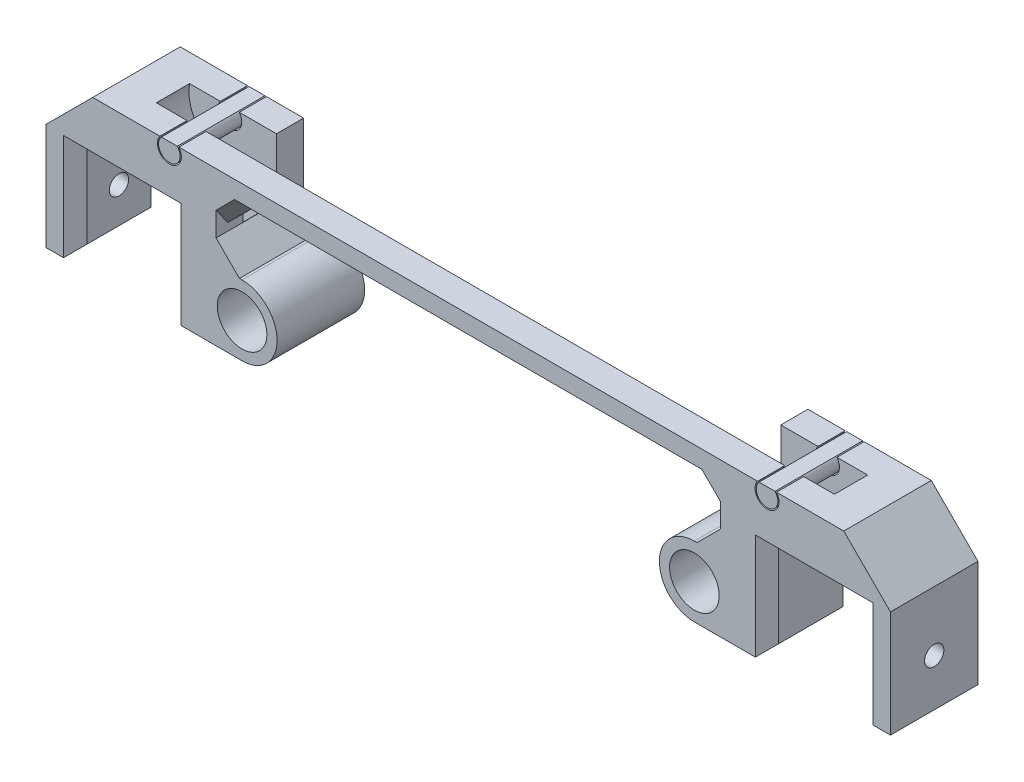
from build123d import *

# Parameters (mm, degrees)
BOSS_EXTRUDE1_DEPTH       = 19.05
M5X0_8_TAPPED_HOLE1_D     = 4.2
M5X0_8_TAPPED_HOLE1_DEPTH = 6.35
SKETCH2_R                 = 8.89
CUT_EXTRUDE1_DEPTH        = 3.6195
BOSS_EXTRUDE2_DEPTH       = 19.05
BOSS_EXTRUDE2_2_DEPTH     = 19.05
CHAMFER1_SIZE             = 2.54
CHAMFER2_SIZE             = 10.16
CHAMFER1_OF_MIRROR1_SIZE  = 2.54
CHAMFER2_OF_MIRROR1_SIZE  = 10.16
SKETCH4_W                 = 109.728
SKETCH4_H                 = 13.1445
CUT_EXTRUDE2_DEPTH        = 34.3883
CHAMFER3_SIZE             = 2.54
CHAMFER6_SIZE             = 5.08
SKETCH5_R                 = 5.3975
BOSS_EXTRUDE3_DEPTH       = 19.05
SKETCH6_R                 = 1.905
BOSS_EXTRUDE4_DEPTH       = 1.778
BOSS_EXTRUDE4_TAPER       = 22.5
CHAMFER7_SIZE             = 5.08
CHAMFER4_SIZE             = 2.54
CHAMFER5_SIZE             = 2.54


with BuildPart() as part:
    # Sketch1 → Boss-Extrude1 (new body)
    with BuildSketch(Plane.XY):
        with BuildLine():
            Line((-54.864, -27.0383), (-54.864, 0))
            Line((-54.864, 0), (54.864, 0))
            Line((54.864, 0), (54.864, -27.0383))
            Line((54.864, -27.0383), (65.024, -27.0383))
            Line((65.024, -27.0383), (65.024, -6.5405))
            Line((65.024, -6.5405), (85.5218, -6.5405))
            Line((85.5218, -6.5405), (85.5218, -27.0383))
            Line((85.5218, -27.0383), (91.8718, -27.0383))
            Line((91.8718, -27.0383), (91.8718, 6.35))
            Line((91.8718, 6.35), (67.087505755, 6.35))
            ThreePointArc((67.087505755, 6.35), (67.488807242, 5.600913686), (67.6275, 4.7625))
            ThreePointArc((67.6275, 4.7625), (64.185586314, 2.297692758), (62.960494245, 6.35))
            Line((62.960494245, 6.35), (-62.960494245, 6.35))
            ThreePointArc((-62.960494245, 6.35), (-62.559192758, 5.600913686), (-62.4205, 4.7625))
            ThreePointArc((-62.4205, 4.7625), (-65.862413686, 2.297692758), (-67.087505755, 6.35))
            Line((-67.087505755, 6.35), (-91.8718, 6.35))
            Line((-91.8718, 6.35), (-91.8718, -27.0383))
            Line((-91.8718, -27.0383), (-85.5218, -27.0383))
            Line((-85.5218, -27.0383), (-85.5218, -6.5405))
            Line((-85.5218, -6.5405), (-65.024, -6.5405))
            Line((-65.024, -6.5405), (-65.024, -27.0383))
            Line((-65.024, -27.0383), (-54.864, -27.0383))
        make_face()
    extrude(amount=BOSS_EXTRUDE1_DEPTH)

    # M5x0.8 Tapped Hole1
    with Locations(Plane(origin=(91.8718, 0, 0), x_dir=(0, 0, -1), z_dir=(1, 0, 0))):
        with Locations((-9.525, -16.7894)):
            m5x0_8_tapped_hole1 = Hole(M5X0_8_TAPPED_HOLE1_D / 2, depth=M5X0_8_TAPPED_HOLE1_DEPTH)

    # Sketch2 → Cut-Extrude1 (cut, symmetric)
    with BuildSketch(Plane.XY.offset(9.525)):
        Polygon((0, 13.6525), (56.134, 13.6525), (56.134, 4.7625), (56.134, -4.1275), (0, -4.1275), align=None)
        with BuildLine():
            Line((56.134, 13.6525), (56.134, 4.7625))
            ThreePointArc((56.134, 4.7625), (58.737820715, 11.048679285), (65.024, 13.6525))
            Line((65.024, 13.6525), (56.134, 13.6525))
        make_face()
        with Locations((65.024, 4.7625)):
            Circle(SKETCH2_R)
        with BuildLine():
            Line((56.134, -4.1275), (65.024, -4.1275))
            ThreePointArc((65.024, -4.1275), (58.737820715, -1.523679285), (56.134, 4.7625))
            Line((56.134, 4.7625), (56.134, -4.1275))
        make_face()
    cut_extrude1 = extrude(amount=CUT_EXTRUDE1_DEPTH, both=True, mode=Mode.SUBTRACT)

    # Chamfer1
    chamfer1_edges = [part.edges().sort_by_distance(p)[0] for p in [
        (85.5218, -27.0383, 9.525),
        (65.024, -27.0383, 9.525),
    ]]
    chamfer(chamfer1_edges, length=CHAMFER1_SIZE)

    # Chamfer2
    chamfer2_edges = [part.edges().sort_by_distance(p)[0] for p in [
        (91.8718, 6.35, 9.525),
    ]]
    chamfer(chamfer2_edges, length=CHAMFER2_SIZE)

    # Mirror1: M5x0.8 Tapped Hole1, Cut-Extrude1 across plane
    add(m5x0_8_tapped_hole1.mirror(Plane(origin=(0, 0, 0), x_dir=(0, 0, 1), z_dir=(1, 0, 0))), mode=Mode.SUBTRACT)
    add(cut_extrude1.mirror(Plane(origin=(0, 0, 0), x_dir=(0, 0, 1), z_dir=(1, 0, 0))), mode=Mode.SUBTRACT)

    # Chamfer1 of Mirror1
    chamfer1_of_mirror1_edges = [part.edges().sort_by_distance(p)[0] for p in [
        (-85.5218, -27.0383, 9.525),
        (-65.024, -27.0383, 9.525),
    ]]
    chamfer(chamfer1_of_mirror1_edges, length=CHAMFER1_OF_MIRROR1_SIZE)

    # Chamfer2 of Mirror1
    chamfer2_of_mirror1_edges = [part.edges().sort_by_distance(p)[0] for p in [
        (-91.8718, 6.35, 9.525),
    ]]
    chamfer(chamfer2_of_mirror1_edges, length=CHAMFER2_OF_MIRROR1_SIZE)

    # Sketch4 → Cut-Extrude2 (cut, through all)
    with BuildSketch(Plane(origin=(0, 6.35, 0), x_dir=(1, 0, 0), z_dir=(0, 1, 0))):
        with Locations((0, -6.57225)):
            Rectangle(SKETCH4_W, SKETCH4_H)
    extrude(amount=-CUT_EXTRUDE2_DEPTH, mode=Mode.SUBTRACT)

    # Chamfer3
    chamfer3_edges = [part.edges().sort_by_distance(p)[0] for p in [
        (-54.864, -4.1275, 9.525),
        (54.864, -4.1275, 9.525),
    ]]
    chamfer(chamfer3_edges, length=CHAMFER3_SIZE)

    # Chamfer6
    chamfer6_edges = [part.edges().sort_by_distance(p)[0] for p in [
        (54.864, 0, 16.09725),
        (-54.864, 0, 16.09725),
    ]]
    chamfer(chamfer6_edges, length=CHAMFER6_SIZE)

    # Sketch5 → Boss-Extrude3 (add)
    with BuildSketch(Plane.XY.offset(19.05)):
        with BuildLine():
            Line((-54.864, -27.0383), (-49.2125, -27.0383))
            ThreePointArc((-49.2125, -27.0383), (-41.5925, -19.4183), (-49.2125, -11.7983))
            Line((-49.2125, -11.7983), (-54.864, -11.7983))
            Line((-54.864, -11.7983), (-54.864, -27.0383))
        make_face()
        with Locations((-49.2125, -19.4183)):
            Circle(SKETCH5_R, mode=Mode.SUBTRACT)
    boss_extrude3 = extrude(amount=-BOSS_EXTRUDE3_DEPTH)

    # Sketch6 → Boss-Extrude4 (add)
    with BuildSketch(Plane.XZ.offset(14.0208)):
        with Locations((-49.2125, 3.57123405)):
            Circle(SKETCH6_R)
    boss_extrude4 = extrude(amount=BOSS_EXTRUDE4_DEPTH, taper=BOSS_EXTRUDE4_TAPER)

    # Mirror5: Boss-Extrude3, Boss-Extrude4 across plane
    add(boss_extrude3.mirror(Plane(origin=(0, 0, 0), x_dir=(0, 0, 1), z_dir=(1, 0, 0))))
    add(boss_extrude4.mirror(Plane(origin=(0, 0, 0), x_dir=(0, 0, 1), z_dir=(1, 0, 0))))

    # Chamfer7
    chamfer7_edges = [part.edges().sort_by_distance(p)[0] for p in [
        (-54.864, -11.7983, 9.525),
        (54.864, -11.7983, 9.525),
    ]]
    chamfer(chamfer7_edges, length=CHAMFER7_SIZE)

    # Chamfer4
    chamfer4_edges = [part.edges().sort_by_distance(p)[0] for p in [
        (0, 0, 13.1445),
        (0, 0, 19.05),
        (-52.324, -2.54, 19.05),
        (52.324, -2.54, 19.05),
    ]]
    chamfer(chamfer4_edges, length=CHAMFER4_SIZE)

    # Chamfer5
    chamfer5_edges = [part.edges().sort_by_distance(p)[0] for p in [
        (-85.5218, -15.5194, 0),
        (-75.2729, -6.5405, 0),
        (-65.024, -15.5194, 0),
        (-65.024, -15.5194, 19.05),
        (-75.2729, -6.5405, 19.05),
        (-85.5218, -15.5194, 19.05),
        (85.5218, -15.5194, 0),
        (85.5218, -15.5194, 19.05),
        (75.2729, -6.5405, 0),
        (75.2729, -6.5405, 19.05),
        (65.024, -15.5194, 19.05),
        (65.024, -15.5194, 0),
    ]]
    chamfer(chamfer5_edges, length=CHAMFER5_SIZE)


with BuildPart() as body_2:
    # Sketch3 → Boss-Extrude2 (new body)
    with BuildSketch(Plane.XY.offset(19.05)):
        with BuildLine():
            Line((66.756049076, 6.35), (63.291950924, 6.35))
            ThreePointArc((63.291950924, 6.35), (64.172324901, 2.572796875), (67.3735, 4.7625))
            ThreePointArc((67.3735, 4.7625), (67.213703125, 5.614175099), (66.756049076, 6.35))
        make_face()
    boss_extrude2 = extrude(amount=-BOSS_EXTRUDE2_DEPTH)


with BuildPart() as body_3:
    # Sketch3 → Boss-Extrude2 2 (new body)
    with BuildSketch(Plane.XY.offset(19.05)):
        with BuildLine():
            ThreePointArc((-62.6745, 4.7625), (-62.834296875, 5.614175099), (-63.291950924, 6.35))
            Line((-63.291950924, 6.35), (-66.756049076, 6.35))
            ThreePointArc((-66.756049076, 6.35), (-65.875675099, 2.572796875), (-62.6745, 4.7625))
        make_face()
    boss_extrude2_2 = extrude(amount=-BOSS_EXTRUDE2_2_DEPTH)


with BuildPart() as body_2_1:
    add(body_2.part)

    add(body_3.part)  # Mirror1 2 merges body 3
    # Mirror1 2: Boss-Extrude2, Boss-Extrude2 2 across plane
    add(boss_extrude2.mirror(Plane(origin=(0, 0, 0), x_dir=(0, 0, 1), z_dir=(1, 0, 0))))
    add(boss_extrude2_2.mirror(Plane(origin=(0, 0, 0), x_dir=(0, 0, 1), z_dir=(1, 0, 0))))


solid = Compound([part.part, body_2_1.part])
